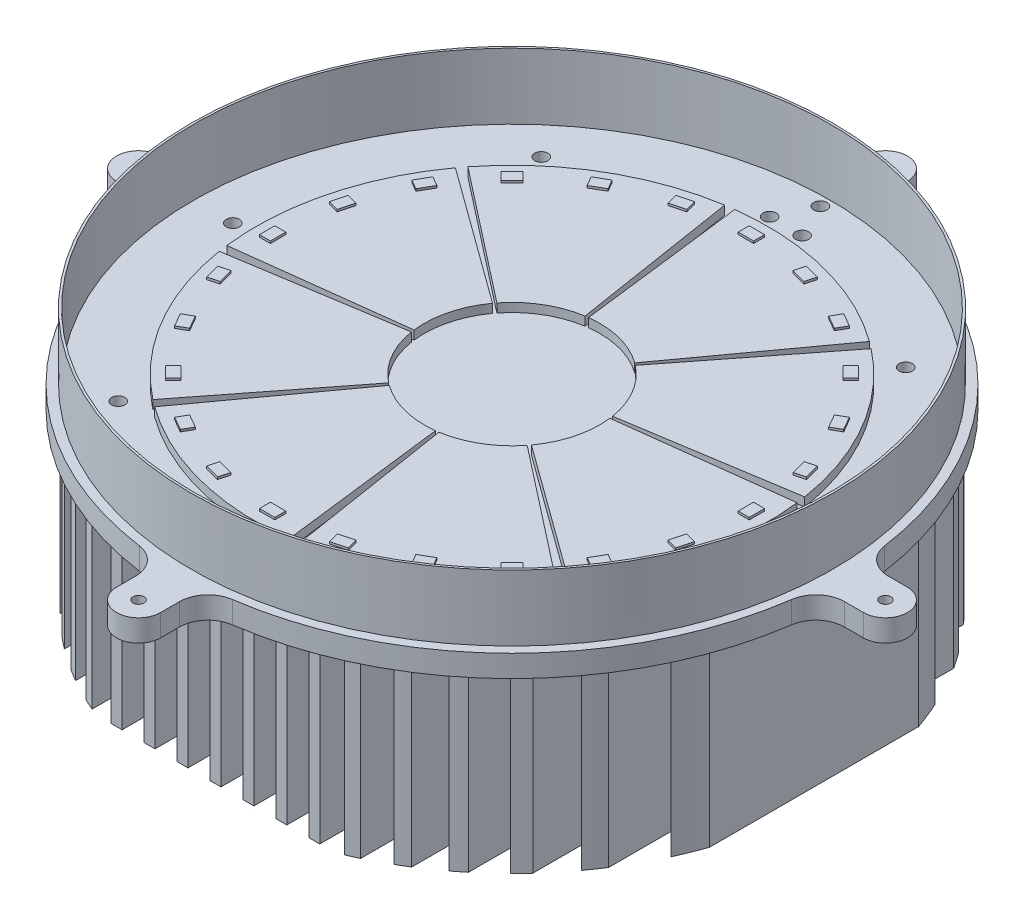
from build123d import *

# Parameters (mm, degrees)
SKETCH2_R           = 146
SKETCH2_R_2         = 145
BOSS_EXTRUDE2_DEPTH = 30
SKETCH3_R           = 2.5
BOSS_EXTRUDE4_DEPTH = 10
SKETCH4_W           = 5
SKETCH4_H           = 270
BOSS_EXTRUDE5_DEPTH = 80
BOSS_EXTRUDE7_DEPTH = 4
BOSS_EXTRUDE6_DEPTH = 1
SKETCH7_R           = 3
CUT_EXTRUDE1_DEPTH  = 10


with BuildPart() as part:
    # Sketch2 → Boss-Extrude2 (new body)
    with BuildSketch(Plane(origin=(0, 0, 0), x_dir=(1, 0, 0), z_dir=(0, 1, 0))):
        Circle(SKETCH2_R)
        Circle(SKETCH2_R_2, mode=Mode.SUBTRACT)
    extrude(amount=BOSS_EXTRUDE2_DEPTH)

    # Sketch3 → Boss-Extrude4 (add)
    with BuildSketch(Plane(origin=(0, 0, 0), x_dir=(1, 0, 0), z_dir=(0, 1, 0))):
        with BuildLine():
            Line((161.369142032, 10), (170, 10))
            ThreePointArc((170, 10), (180, 0), (170, -10))
            Line((170, -10), (161.369142032, -10))
            ThreePointArc((161.369142032, -10), (152.849946816, -13.180462695), (148.499210458, -21.165644172))
            ThreePointArc((148.499210458, -21.165644172), (106.066017178, -106.066017178), (21.165644172, -148.499210458))
            ThreePointArc((21.165644172, -148.499210458), (13.180462695, -152.849946816), (10, -161.369142032))
            Line((10, -161.369142032), (10, -170))
            ThreePointArc((10, -170), (0, -180), (-10, -170))
            Line((-10, -170), (-10, -161.369142032))
            ThreePointArc((-10, -161.369142032), (-13.180462695, -152.849946816), (-21.165644172, -148.499210458))
            ThreePointArc((-21.165644172, -148.499210458), (-106.066017178, -106.066017178), (-148.499210458, -21.165644172))
            ThreePointArc((-148.499210458, -21.165644172), (-152.849946816, -13.180462695), (-161.369142032, -10))
            Line((-161.369142032, -10), (-170, -10))
            ThreePointArc((-170, -10), (-180, 0), (-170, 10))
            Line((-170, 10), (-161.369142032, 10))
            ThreePointArc((-161.369142032, 10), (-152.849946816, 13.180462695), (-148.499210458, 21.165644172))
            ThreePointArc((-148.499210458, 21.165644172), (-106.066017178, 106.066017178), (-21.165644172, 148.499210458))
            ThreePointArc((-21.165644172, 148.499210458), (-13.180462695, 152.849946816), (-10, 161.369142032))
            Line((-10, 161.369142032), (-10, 170))
            ThreePointArc((-10, 170), (0, 180), (10, 170))
            Line((10, 170), (10, 161.369142032))
            ThreePointArc((10, 161.369142032), (13.180462695, 152.849946816), (21.165644172, 148.499210458))
            ThreePointArc((21.165644172, 148.499210458), (106.066017178, 106.066017178), (148.499210458, 21.165644172))
            ThreePointArc((148.499210458, 21.165644172), (152.849946816, 13.180462695), (161.369142032, 10))
        make_face()
        with Locations((0, 170)):
            Circle(SKETCH3_R, mode=Mode.SUBTRACT)
        with Locations((170, 0)):
            Circle(SKETCH3_R, mode=Mode.SUBTRACT)
        with Locations((0, -170)):
            Circle(SKETCH3_R, mode=Mode.SUBTRACT)
        with Locations((-170, 0)):
            Circle(SKETCH3_R, mode=Mode.SUBTRACT)
    extrude(amount=-BOSS_EXTRUDE4_DEPTH)

    # Sketch4 → Boss-Extrude5 (add)
    with BuildSketch(Plane.XZ.offset(10)):
        Rectangle(SKETCH4_W, SKETCH4_H)
        with Locations((15, 0)):
            Rectangle(SKETCH4_W, SKETCH4_H)
        with Locations((30, 0)):
            Rectangle(SKETCH4_W, SKETCH4_H)
        with Locations((45, 0)):
            Rectangle(SKETCH4_W, SKETCH4_H)
        with BuildLine():
            Line((57.5, -133.656275573), (57.5, 133.656275573))
            ThreePointArc((57.5, 133.656275573), (60.010675074, 132.547987073), (62.5, 131.392541645))
            Line((62.5, 131.392541645), (62.5, -131.392541645))
            ThreePointArc((62.5, -131.392541645), (60.010675074, -132.547987073), (57.5, -133.656275573))
        make_face()
        with BuildLine():
            Line((72.5, -126.150703526), (72.5, 126.150703526))
            ThreePointArc((72.5, 126.150703526), (75.015083697, 124.671517268), (77.5, 123.142194231))
            Line((77.5, 123.142194231), (77.5, -123.142194231))
            ThreePointArc((77.5, -123.142194231), (75.015083697, -124.671517268), (72.5, -126.150703526))
        make_face()
        with BuildLine():
            Line((87.5, -116.249731182), (87.5, 116.249731182))
            ThreePointArc((87.5, 116.249731182), (90.021532442, 114.308239846), (92.5, 112.312065247))
            Line((92.5, 112.312065247), (92.5, -112.312065247))
            ThreePointArc((92.5, -112.312065247), (90.021532442, -114.308239846), (87.5, -116.249731182))
        make_face()
        with BuildLine():
            Line((102.5, -103.266645147), (102.5, 103.266645147))
            ThreePointArc((102.5, 103.266645147), (105.032379388, 100.689866819), (107.5, 98.051007134))
            Line((107.5, 98.051007134), (107.5, -98.051007134))
            ThreePointArc((107.5, -98.051007134), (105.032379388, -100.689866819), (102.5, -103.266645147))
        make_face()
        with BuildLine():
            Line((117.5, -85.813751812), (117.5, 85.813751812))
            ThreePointArc((117.5, 85.813751812), (120.055537207, 82.200474366), (122.5, 78.511145706))
            Line((122.5, 78.511145706), (122.5, -78.511145706))
            ThreePointArc((122.5, -78.511145706), (120.055537207, -82.200474366), (117.5, -85.813751812))
        make_face()
        with BuildLine():
            Line((132.5, -60.116553461), (132.5, 60.116553461))
            ThreePointArc((132.5, 60.116553461), (135.145409966, 53.907032613), (137.5, 47.581509013))
            Line((137.5, 47.581509013), (137.5, -47.581509013))
            ThreePointArc((137.5, -47.581509013), (135.145409966, -53.907032613), (132.5, -60.116553461))
        make_face()
        with Locations((-15, 0)):
            Rectangle(SKETCH4_W, SKETCH4_H)
        with Locations((-30, 0)):
            Rectangle(SKETCH4_W, SKETCH4_H)
        with Locations((-45, 0)):
            Rectangle(SKETCH4_W, SKETCH4_H)
        with BuildLine():
            Line((-57.5, -133.656275573), (-57.5, 133.656275573))
            ThreePointArc((-57.5, 133.656275573), (-60.010675074, 132.547987073), (-62.5, 131.392541645))
            Line((-62.5, 131.392541645), (-62.5, -131.392541645))
            ThreePointArc((-62.5, -131.392541645), (-60.010675074, -132.547987073), (-57.5, -133.656275573))
        make_face()
        with BuildLine():
            Line((-72.5, -126.150703526), (-72.5, 126.150703526))
            ThreePointArc((-72.5, 126.150703526), (-75.015083697, 124.671517268), (-77.5, 123.142194231))
            Line((-77.5, 123.142194231), (-77.5, -123.142194231))
            ThreePointArc((-77.5, -123.142194231), (-75.015083697, -124.671517268), (-72.5, -126.150703526))
        make_face()
        with BuildLine():
            Line((-87.5, -116.249731182), (-87.5, 116.249731182))
            ThreePointArc((-87.5, 116.249731182), (-90.021532442, 114.308239846), (-92.5, 112.312065247))
            Line((-92.5, 112.312065247), (-92.5, -112.312065247))
            ThreePointArc((-92.5, -112.312065247), (-90.021532442, -114.308239846), (-87.5, -116.249731182))
        make_face()
        with BuildLine():
            Line((-102.5, -103.266645147), (-102.5, 103.266645147))
            ThreePointArc((-102.5, 103.266645147), (-105.032379388, 100.689866819), (-107.5, 98.051007134))
            Line((-107.5, 98.051007134), (-107.5, -98.051007134))
            ThreePointArc((-107.5, -98.051007134), (-105.032379388, -100.689866819), (-102.5, -103.266645147))
        make_face()
        with BuildLine():
            Line((-117.5, -85.813751812), (-117.5, 85.813751812))
            ThreePointArc((-117.5, 85.813751812), (-120.055537207, 82.200474366), (-122.5, 78.511145706))
            Line((-122.5, 78.511145706), (-122.5, -78.511145706))
            ThreePointArc((-122.5, -78.511145706), (-120.055537207, -82.200474366), (-117.5, -85.813751812))
        make_face()
        with BuildLine():
            Line((-132.5, -60.116553461), (-132.5, 60.116553461))
            ThreePointArc((-132.5, 60.116553461), (-135.145409966, 53.907032613), (-137.5, 47.581509013))
            Line((-137.5, 47.581509013), (-137.5, -47.581509013))
            ThreePointArc((-137.5, -47.581509013), (-135.145409966, -53.907032613), (-132.5, -60.116553461))
        make_face()
    extrude(amount=BOSS_EXTRUDE5_DEPTH)

    # Sketch8 → Boss-Extrude7 (add)
    with BuildSketch(Plane(origin=(0, 0, 0), x_dir=(1, 0, 0), z_dir=(0, 1, 0))):
        with BuildLine():
            Line((4.874773736, -39.701846066), (14.194376054, -115.603915915))
            ThreePointArc((14.194376054, -115.603915915), (-29.162280149, -112.762170531), (-68.460571601, -94.227893017))
            Line((-68.460571601, -94.227893017), (-23.511410092, -32.360679775))
            ThreePointArc((-23.511410092, -32.360679775), (-10.015200162, -38.725905615), (4.874773736, -39.701846066))
        make_face()
        with BuildLine():
            Line((-24.626459013, -31.520430144), (-71.707373312, -91.781252438))
            ThreePointArc((-71.707373312, -91.781252438), (-100.355741492, -59.114049395), (-115.038116552, -18.220247706))
            Line((-115.038116552, -18.220247706), (-39.507533624, -6.257378602))
            ThreePointArc((-39.507533624, -6.257378602), (-34.465166418, -20.301534518), (-24.626459013, -31.520430144))
        make_face()
        with BuildLine():
            Line((-39.701846066, -4.874773736), (-115.603915915, -14.194376054))
            ThreePointArc((-115.603915915, -14.194376054), (-112.762170531, 29.162280149), (-94.227893017, 68.460571601))
            Line((-94.227893017, 68.460571601), (-32.360679775, 23.511410092))
            ThreePointArc((-32.360679775, 23.511410092), (-38.725905615, 10.015200162), (-39.701846066, -4.874773736))
        make_face()
        with BuildLine():
            Line((-31.520430144, 24.626459013), (-91.781252438, 71.707373312))
            ThreePointArc((-91.781252438, 71.707373312), (-59.114049395, 100.355741492), (-18.220247706, 115.038116552))
            Line((-18.220247706, 115.038116552), (-6.257378602, 39.507533624))
            ThreePointArc((-6.257378602, 39.507533624), (-20.301534518, 34.465166418), (-31.520430144, 24.626459013))
        make_face()
        with BuildLine():
            Line((-4.874773736, 39.701846066), (-14.194376054, 115.603915915))
            ThreePointArc((-14.194376054, 115.603915915), (29.162280149, 112.762170531), (68.460571601, 94.227893017))
            Line((68.460571601, 94.227893017), (23.511410092, 32.360679775))
            ThreePointArc((23.511410092, 32.360679775), (10.015200162, 38.725905615), (-4.874773736, 39.701846066))
        make_face()
        with BuildLine():
            Line((24.626459013, 31.520430144), (71.707373312, 91.781252438))
            ThreePointArc((71.707373312, 91.781252438), (100.355741492, 59.114049395), (115.038116552, 18.220247706))
            Line((115.038116552, 18.220247706), (39.507533624, 6.257378602))
            ThreePointArc((39.507533624, 6.257378602), (34.465166418, 20.301534518), (24.626459013, 31.520430144))
        make_face()
        with BuildLine():
            Line((39.701846066, 4.874773736), (115.603915915, 14.194376054))
            ThreePointArc((115.603915915, 14.194376054), (112.762170531, -29.162280149), (94.227893017, -68.460571601))
            Line((94.227893017, -68.460571601), (32.360679775, -23.511410092))
            ThreePointArc((32.360679775, -23.511410092), (38.725905615, -10.015200162), (39.701846066, 4.874773736))
        make_face()
        with BuildLine():
            Line((31.520430144, -24.626459013), (91.781252438, -71.707373312))
            ThreePointArc((91.781252438, -71.707373312), (59.114049395, -100.355741492), (18.220247706, -115.038116552))
            Line((18.220247706, -115.038116552), (6.257378602, -39.507533624))
            ThreePointArc((6.257378602, -39.507533624), (20.301534518, -34.465166418), (31.520430144, -24.626459013))
        make_face()
    extrude(amount=BOSS_EXTRUDE7_DEPTH)

    # Sketch5 → Boss-Extrude6 (add)
    with BuildSketch(Plane(origin=(0, 4, 0), x_dir=(1, 0, 0), z_dir=(0, 1, 0))):
        Polygon((0, 111.478572259), (3.5, 111.478572259), (3.5, 106.478572259), (0, 106.478572259), (-3.5, 106.478572259), (-3.5, 111.478572259), align=None)
        Polygon((24.177942004, 103.756269549), (25.472037229, 108.585898681), (28.852777621, 107.680032023), (32.233518013, 106.774165365), (30.939422788, 101.944536234), (27.558682396, 102.850402891), align=None)
        Polygon((50.208197216, 93.963148535), (52.708197216, 98.293275554), (55.73928613, 96.543275554), (58.770375043, 94.793275554), (56.270375043, 90.463148535), (53.23928613, 92.213148535), align=None)
        Polygon((72.816846761, 77.76659423), (76.352380667, 81.302128135), (78.827254401, 78.827254401), (81.302128135, 76.352380667), (77.76659423, 72.816846761), (75.291720495, 75.291720495), align=None)
        Polygon((90.463148535, 56.270375043), (94.793275554, 58.770375043), (96.543275554, 55.73928613), (98.293275554, 52.708197216), (93.963148535, 50.208197216), (92.213148535, 53.23928613), align=None)
        Polygon((101.944536234, 30.939422788), (106.774165365, 32.233518013), (107.680032023, 28.852777621), (108.585898681, 25.472037229), (103.756269549, 24.177942004), (102.850402891, 27.558682396), align=None)
        Polygon((106.478572259, 3.5), (111.478572259, 3.5), (111.478572259, 0), (111.478572259, -3.5), (106.478572259, -3.5), (106.478572259, 0), align=None)
        Polygon((103.756269549, -24.177942004), (108.585898681, -25.472037229), (107.680032023, -28.852777621), (106.774165365, -32.233518013), (101.944536234, -30.939422788), (102.850402891, -27.558682396), align=None)
        Polygon((93.963148535, -50.208197216), (98.293275554, -52.708197216), (96.543275554, -55.73928613), (94.793275554, -58.770375043), (90.463148535, -56.270375043), (92.213148535, -53.23928613), align=None)
        Polygon((77.76659423, -72.816846761), (81.302128135, -76.352380667), (78.827254401, -78.827254401), (76.352380667, -81.302128135), (72.816846761, -77.76659423), (75.291720495, -75.291720495), align=None)
        Polygon((56.270375043, -90.463148535), (58.770375043, -94.793275554), (55.73928613, -96.543275554), (52.708197216, -98.293275554), (50.208197216, -93.963148535), (53.23928613, -92.213148535), align=None)
        Polygon((30.939422788, -101.944536234), (32.233518013, -106.774165365), (28.852777621, -107.680032023), (25.472037229, -108.585898681), (24.177942004, -103.756269549), (27.558682396, -102.850402891), align=None)
        Polygon((3.5, -106.478572259), (3.5, -111.478572259), (0, -111.478572259), (-3.5, -111.478572259), (-3.5, -106.478572259), (0, -106.478572259), align=None)
        Polygon((-24.177942004, -103.756269549), (-25.472037229, -108.585898681), (-28.852777621, -107.680032023), (-32.233518013, -106.774165365), (-30.939422788, -101.944536234), (-27.558682396, -102.850402891), align=None)
        Polygon((-50.208197216, -93.963148535), (-52.708197216, -98.293275554), (-55.73928613, -96.543275554), (-58.770375043, -94.793275554), (-56.270375043, -90.463148535), (-53.23928613, -92.213148535), align=None)
        Polygon((-72.816846761, -77.76659423), (-76.352380667, -81.302128135), (-78.827254401, -78.827254401), (-81.302128135, -76.352380667), (-77.76659423, -72.816846761), (-75.291720495, -75.291720495), align=None)
        Polygon((-90.463148535, -56.270375043), (-94.793275554, -58.770375043), (-96.543275554, -55.73928613), (-98.293275554, -52.708197216), (-93.963148535, -50.208197216), (-92.213148535, -53.23928613), align=None)
        Polygon((-101.944536234, -30.939422788), (-106.774165365, -32.233518013), (-107.680032023, -28.852777621), (-108.585898681, -25.472037229), (-103.756269549, -24.177942004), (-102.850402891, -27.558682396), align=None)
        Polygon((-106.478572259, -3.5), (-111.478572259, -3.5), (-111.478572259, 0), (-111.478572259, 3.5), (-106.478572259, 3.5), (-106.478572259, 0), align=None)
        Polygon((-103.756269549, 24.177942004), (-108.585898681, 25.472037229), (-107.680032023, 28.852777621), (-106.774165365, 32.233518013), (-101.944536234, 30.939422788), (-102.850402891, 27.558682396), align=None)
        Polygon((-93.963148535, 50.208197216), (-98.293275554, 52.708197216), (-96.543275554, 55.73928613), (-94.793275554, 58.770375043), (-90.463148535, 56.270375043), (-92.213148535, 53.23928613), align=None)
        Polygon((-77.76659423, 72.816846761), (-81.302128135, 76.352380667), (-78.827254401, 78.827254401), (-76.352380667, 81.302128135), (-72.816846761, 77.76659423), (-75.291720495, 75.291720495), align=None)
        Polygon((-56.270375043, 90.463148535), (-58.770375043, 94.793275554), (-55.73928613, 96.543275554), (-52.708197216, 98.293275554), (-50.208197216, 93.963148535), (-53.23928613, 92.213148535), align=None)
        Polygon((-30.939422788, 101.944536234), (-32.233518013, 106.774165365), (-28.852777621, 107.680032023), (-25.472037229, 108.585898681), (-24.177942004, 103.756269549), (-27.558682396, 102.850402891), align=None)
    extrude(amount=BOSS_EXTRUDE6_DEPTH)

    # Sketch7 → Cut-Extrude1 (cut)
    with BuildSketch(Plane(origin=(0, 0, 0), x_dir=(1, 0, 0), z_dir=(0, 1, 0))):
        with Locations((-127.088241501, 0)):
            Circle(SKETCH7_R)
        with Locations((0, 140.377871213)):
            Circle(SKETCH7_R)
        with Locations((0, -140.377871213)):
            Circle(SKETCH7_R)
        with Locations((127.088241501, 0)):
            Circle(SKETCH7_R)
        with Locations((-67.712428911, 0)):
            Circle(SKETCH7_R)
        with Locations((-52.130916661, 49.662536464)):
            Circle(SKETCH7_R)
        with Locations((52.130916661, 49.662536464)):
            Circle(SKETCH7_R)
        with Locations((52.130916661, -49.662536464)):
            Circle(SKETCH7_R)
        with Locations((-52.130916661, -49.662536464)):
            Circle(SKETCH7_R)
        with Locations((67.712428911, 0)):
            Circle(SKETCH7_R)
        with Locations((-82.954299453, 96.280866896)):
            Circle(SKETCH7_R)
        with Locations((82.954299453, 96.280866896)):
            Circle(SKETCH7_R)
        with Locations((82.954299453, -96.280866896)):
            Circle(SKETCH7_R)
        with Locations((-82.954299453, -96.280866896)):
            Circle(SKETCH7_R)
        with Locations((7.399863504, -124.662387406)):
            Circle(SKETCH7_R)
        with Locations((-7.399863504, -124.662387406)):
            Circle(SKETCH7_R)
        with Locations((7.399863504, 124.662387406)):
            Circle(SKETCH7_R)
        with Locations((-7.399863504, 124.662387406)):
            Circle(SKETCH7_R)
    extrude(amount=-CUT_EXTRUDE1_DEPTH, mode=Mode.SUBTRACT)


solid = part.part
